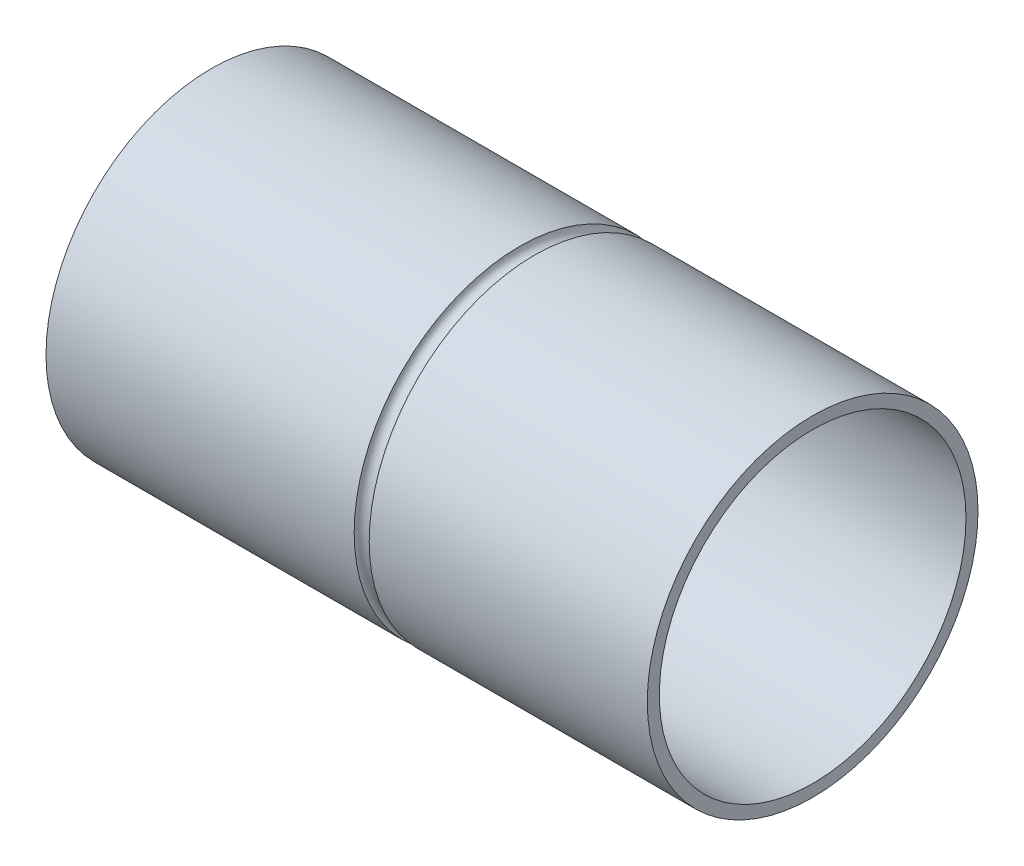
from build123d import *

# Parameters (mm, degrees)
SKETCH1_R               = 55
BOSS_EXTRUDE1_DEPTH     = 200
SKETCH2_R               = 51
CUT_EXTRUDE1_DEPTH      = 190
SKETCH3_R               = 19
CUT_EXTRUDE2_DEPTH      = 1
CUT_EXTRUDE2_DEPTH_BACK = 201
SKETCH4_R               = 5
CUT_EXTRUDE3_DEPTH      = 2
SKETCH5_R               = 22.5
CUT_EXTRUDE4_DEPTH      = 2
CUT_SWEEP1_PROFILE_R    = 2.5
SKETCH58_R              = 2.5
CUT_EXTRUDE5_DEPTH      = 2


with BuildPart() as part:
    # Sketch1 → Boss-Extrude1 (new body)
    with BuildSketch(Plane(origin=(0, 0, 0), x_dir=(0, 0, -1), z_dir=(1, 0, 0))):
        Circle(SKETCH1_R)
    extrude(amount=BOSS_EXTRUDE1_DEPTH)

    # Sketch2 → Cut-Extrude1 (cut)
    with BuildSketch(Plane(origin=(200, 0, 0), x_dir=(0, 0, -1), z_dir=(1, 0, 0))):
        Circle(SKETCH2_R)
    extrude(amount=-CUT_EXTRUDE1_DEPTH, mode=Mode.SUBTRACT)

    # Sketch3 → Cut-Extrude2 (cut, two sides)
    with BuildSketch(Plane.ZY) as cut_extrude2_sk:
        Circle(SKETCH3_R)
    extrude(amount=CUT_EXTRUDE2_DEPTH, mode=Mode.SUBTRACT)
    extrude(cut_extrude2_sk.sketch, amount=-CUT_EXTRUDE2_DEPTH_BACK, mode=Mode.SUBTRACT)

    # Sketch4 → Cut-Extrude3 (cut)
    with BuildSketch(Plane.ZY):
        with Locations((0, 34)):
            Circle(SKETCH4_R)
        with Locations((0, -34)):
            Circle(SKETCH4_R)
    extrude(amount=-CUT_EXTRUDE3_DEPTH, mode=Mode.SUBTRACT)

    # Sketch5 → Cut-Extrude4 (cut)
    with BuildSketch(Plane.ZY):
        Circle(SKETCH5_R)
    extrude(amount=-CUT_EXTRUDE4_DEPTH, mode=Mode.SUBTRACT)

    # Cut-Sweep1: sweep along a path in Sketch57
    with BuildLine(Plane(origin=(105, 0, 0), x_dir=(0, 0, -1), z_dir=(1, 0, 0))) as cut_sweep1_path:
        CenterArc((0, 0), 55, 0, 360)
    # Cut-Sweep1 profile (on start of the path) → Cut-Sweep1 (sweep, cut)
    with BuildSketch(Plane(origin=(105, 0, -55), x_dir=(0, 0, 1), z_dir=(0, 1, 0))):
        Circle(CUT_SWEEP1_PROFILE_R)
    sweep(path=cut_sweep1_path.line, mode=Mode.SUBTRACT)

    # Sketch58 → Cut-Extrude5 (cut)
    with BuildSketch(Plane.ZY.offset(-2)):
        with Locations((0, 34)):
            Circle(SKETCH58_R)
        with Locations((0, -34)):
            Circle(SKETCH58_R)
    extrude(amount=-CUT_EXTRUDE5_DEPTH, mode=Mode.SUBTRACT)


solid = part.part
